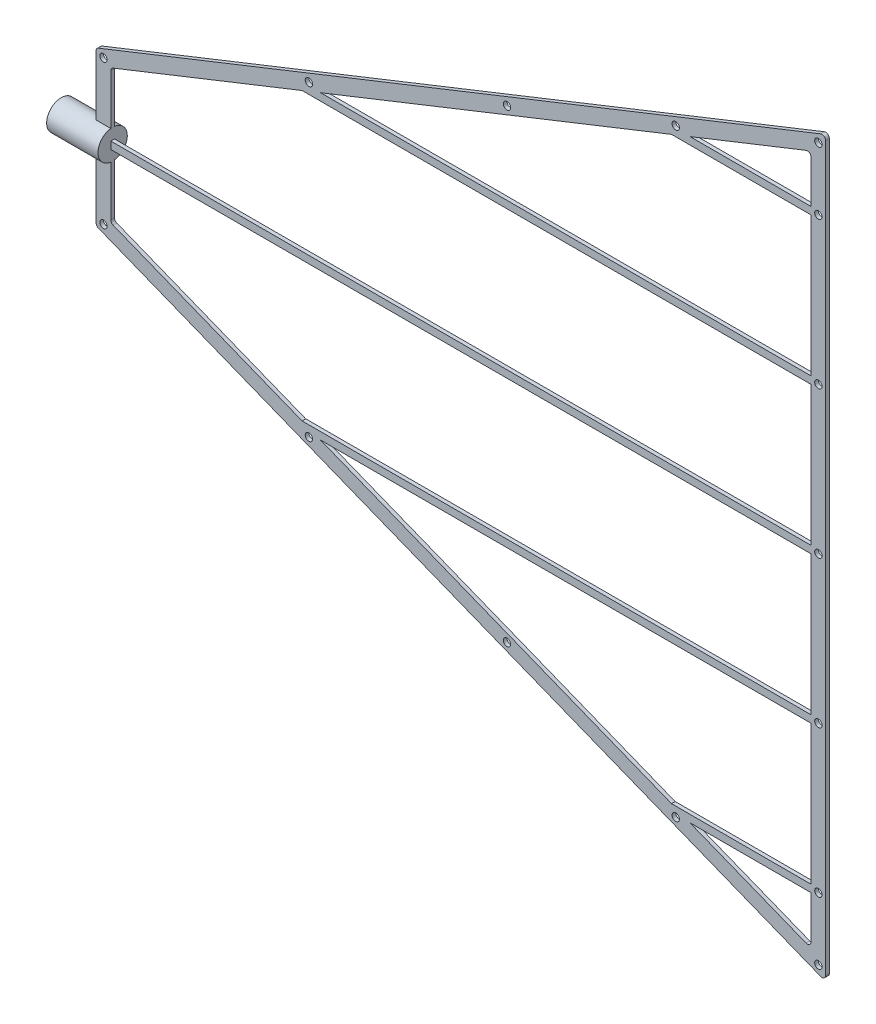
from build123d import *

# Parameters (mm, degrees)
EXTRUDE_1_DEPTH     = 0.25
SKETCH_4_R          = 0.5
CUT_EXTRUDE_1_DEPTH = 0.25
FILLET_1_R          = 0.5


with BuildPart() as part:
    # 草图1 → 凸台-拉伸1 (new body, symmetric)
    with BuildSketch(Plane.XY):
        Polygon((0, -10.5), (0, 10.5), (99.442194264, 50), (99.442194264, -50), align=None)
        Polygon((2, 9.142427382), (28.075436668, 19.5), (97.442194264, 19.5), (97.442194264, 0.5), (2, 0.5), align=None, mode=Mode.SUBTRACT)
        Polygon((97.442194264, 47.053564614), (97.442194264, 40.5), (80.943438681, 40.5), align=None, mode=Mode.SUBTRACT)
        Polygon((97.442194264, -47.053564614), (80.943438681, -40.5), (97.442194264, -40.5), align=None, mode=Mode.SUBTRACT)
        Polygon((2, -9.142427382), (2, -0.5), (97.442194264, -0.5), (97.442194264, -19.5), (28.075436668, -19.5), align=None, mode=Mode.SUBTRACT)
        Polygon((30.592960573, 20.5), (97.442194264, 20.5), (97.442194264, 39.5), (78.425914776, 39.5), align=None, mode=Mode.SUBTRACT)
        Polygon((78.425914776, -39.5), (97.442194264, -39.5), (97.442194264, -20.5), (30.592960573, -20.5), align=None, mode=Mode.SUBTRACT)
    extrude(amount=EXTRUDE_1_DEPTH, both=True)

    # 草图4 → 切除-拉伸1 (cut, symmetric)
    with BuildSketch(Plane.XY):
        with Locations((1, 9.821213691)):
            Circle(SKETCH_4_R)
        with Locations((29, 20.943253065)):
            Circle(SKETCH_4_R)
        with Locations((56, 31.668076746)):
            Circle(SKETCH_4_R)
        with Locations((79, 40.80403766)):
            Circle(SKETCH_4_R)
        with Locations((98.442194264, 48.526782307)):
            Circle(SKETCH_4_R)
        with Locations((98.442194264, 40)):
            Circle(SKETCH_4_R)
        with Locations((98.442194264, 20)):
            Circle(SKETCH_4_R)
        with Locations((98.442194264, 0)):
            Circle(SKETCH_4_R)
        with Locations((98.442194264, -20)):
            Circle(SKETCH_4_R)
        with Locations((98.442194264, -40)):
            Circle(SKETCH_4_R)
        with Locations((98.442194264, -48.526782307)):
            Circle(SKETCH_4_R)
        with Locations((79, -40.80403766)):
            Circle(SKETCH_4_R)
        with Locations((56, -31.668076746)):
            Circle(SKETCH_4_R)
        with Locations((29, -20.943253065)):
            Circle(SKETCH_4_R)
        with Locations((1, -9.821213691)):
            Circle(SKETCH_4_R)
    extrude(amount=CUT_EXTRUDE_1_DEPTH, both=True, mode=Mode.SUBTRACT)

    # 草图5 → 旋转1 (revolve)
    with BuildSketch(Plane.XY):
        Polygon((2, 0), (2, 2), (-5, 2), (-5, 1.9), (0, 1.9), (0, 0), align=None)
    revolve(axis=Axis((0, 0, 0), (-1, 0, 0)))

    # 圆角1
    fillet_1_edges = [part.edges().sort_by_distance(p)[0] for p in [
        (2, 9.142427382, 0),
        (97.442194264, 47.053564614, 0),
        (97.442194264, -47.053564614, 0),
        (2, -9.142427382, 0),
        (99.442194264, 50, 0),
        (99.442194264, -50, 0),
        (0, -10.5, 0),
        (0, 10.5, 0),
    ]]
    fillet(fillet_1_edges, radius=FILLET_1_R)


solid = part.part
